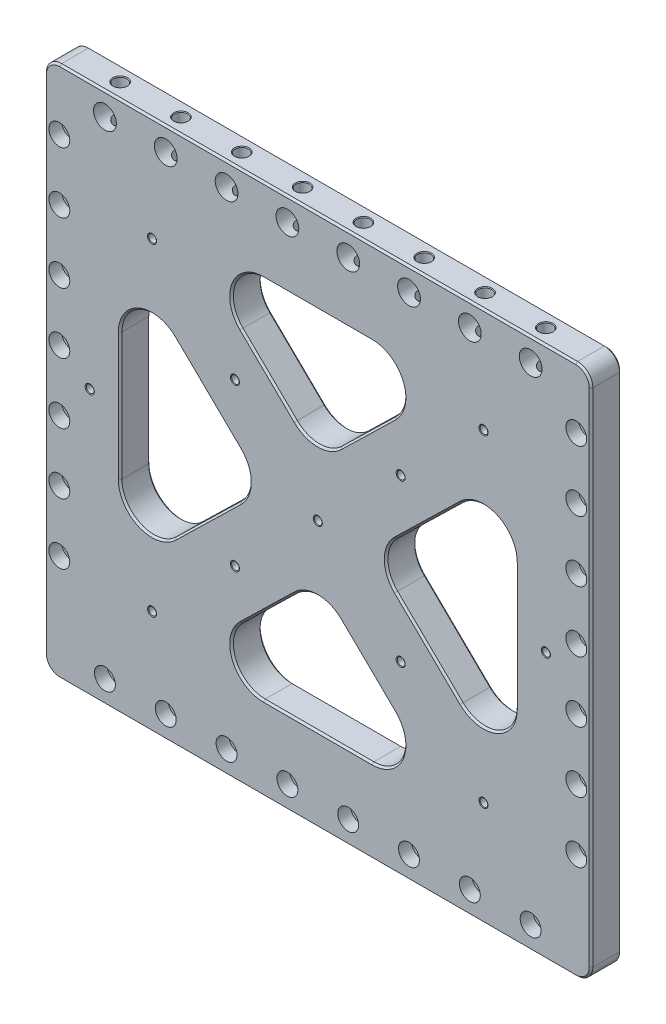
from build123d import *

# Parameters (mm, degrees)
SKETCH1_W                                     = 456.438
SKETCH1_H                                     = 444.5
EXTRUDE1_DEPTH                                = 12.7
CBORE_FOR_3_8_SOCKET_HEAD_CAP_SCREW1_AT_COUNT = 2
CBORE_FOR_3_8_SOCKET_HEAD_CAP_SCREW1_AT_PITCH = 431.8
LPATTERN1_COUNT                               = 4
LPATTERN1_PITCH                               = 50.8
LPATTERN1_COL_COUNT                           = 4
LPATTERN1_COL_PITCH                           = 50.8
TRIANGLES_CUT_EXTRUDE1_DEPTH                  = 26.4
FILLET1_R                                     = 26.67
F_3_4_0_75_DIAMETER_HOLE1_D                   = 19.05
LPATTERN3_COUNT                               = 5
LPATTERN3_PITCH                               = 50.8
LPATTERN3_COL_COUNT                           = 4
LPATTERN3_COL_PITCH                           = 50.8
F_1_4_20_TAPPED_HOLE1_AT_2_COUNT              = 2
F_1_4_20_TAPPED_HOLE1_AT_2_PITCH              = 96.61319845
F_1_4_20_TAPPED_HOLE1_AT_3_COUNT              = 2
F_1_4_20_TAPPED_HOLE1_AT_3_PITCH              = 213.731750641
F_1_4_20_TAPPED_HOLE1_AT_4_COUNT              = 2
F_1_4_20_TAPPED_HOLE1_AT_4_PITCH              = 134.809404563
F_1_4_20_TAPPED_HOLE1_AT_5_COUNT              = 2
F_1_4_20_TAPPED_HOLE1_AT_5_PITCH              = 193.226396899
F_1_4_20_TAPPED_HOLE1_AT_6_COUNT              = 2
F_1_4_20_TAPPED_HOLE1_AT_6_PITCH              = 289.839595349
F_1_4_20_TAPPED_HOLE1_AT_7_COUNT              = 2
F_1_4_20_TAPPED_HOLE1_AT_7_PITCH              = 218.311337119
F_1_4_20_TAPPED_HOLE1_AT_8_COUNT              = 2
F_1_4_20_TAPPED_HOLE1_AT_8_PITCH              = 138.43
F_1_4_20_TAPPED_HOLE1_AT_9_COUNT              = 2
F_1_4_20_TAPPED_HOLE1_AT_9_PITCH              = 96.61319845
F_1_4_20_TAPPED_HOLE1_AT_10_COUNT             = 2
F_1_4_20_TAPPED_HOLE1_AT_10_PITCH             = 268.319352852
F_1_4_20_TAPPED_HOLE1_AT_11_COUNT             = 2
F_1_4_20_TAPPED_HOLE1_AT_11_PITCH             = 138.756784031
FILLET2_R                                     = 12.7
CHAMFER1_SIZE                                 = 1.524


with BuildPart() as part:
    # Sketch1 → Extrude1 (new body, symmetric)
    with BuildSketch(Plane.XY):
        Rectangle(SKETCH1_W, SKETCH1_H)
    extrude(amount=EXTRUDE1_DEPTH, both=True)

    # Sketch2 → CBORE for 3_8 Socket Head Cap Screw1 (revolve, cut)
    with BuildSketch(Plane(origin=(-215.9, 19.05, 12.7), x_dir=(0, -1, 0), z_dir=(1, 0, 0))):
        Polygon((0, 0), (0, 25.4), (5.842, 25.4), (5.15874, 24.613999282), (5.15874, 10.668), (8.7376, 10.668), (8.7376, 0), align=None)
    cbore_for_3_8_socket_head_cap_screw1 = revolve(axis=Axis((-215.9, 19.05, 19.05), (0, 0, -1)), mode=Mode.SUBTRACT)

    # CBORE for 3_8 Socket Head Cap Screw1 at: CBORE for 3_8 Socket Head Cap Screw1 ×2
    with Locations(*[(i * CBORE_FOR_3_8_SOCKET_HEAD_CAP_SCREW1_AT_PITCH, 0, 0) for i in range(1, CBORE_FOR_3_8_SOCKET_HEAD_CAP_SCREW1_AT_COUNT)]):
        add(cbore_for_3_8_socket_head_cap_screw1, mode=Mode.SUBTRACT)

    # LPattern1: CBORE for 3_8 Socket Head Cap Screw1 ×4
    with Locations(*[(0, -i * LPATTERN1_PITCH, 0) for i in range(1, LPATTERN1_COUNT)]):
        add(cbore_for_3_8_socket_head_cap_screw1, mode=Mode.SUBTRACT)

    # LPattern1 copy 1 sketch → LPattern1 copy 1 (revolve, cut)
    with BuildSketch(Plane(origin=(215.9, -31.75, 12.7), x_dir=(0, -1, 0), z_dir=(1, 0, 0))):
        Polygon((0, 0), (0, 25.4), (5.842, 25.4), (5.15874, 24.613999282), (5.15874, 10.668), (8.7376, 10.668), (8.7376, 0), align=None)
    revolve(axis=Axis((215.9, -31.75, 19.05), (0, 0, -1)), mode=Mode.SUBTRACT)

    # LPattern1 copy 2 sketch → LPattern1 copy 2 (revolve, cut)
    with BuildSketch(Plane(origin=(215.9, -82.55, 12.7), x_dir=(0, -1, 0), z_dir=(1, 0, 0))):
        Polygon((0, 0), (0, 25.4), (5.842, 25.4), (5.15874, 24.613999282), (5.15874, 10.668), (8.7376, 10.668), (8.7376, 0), align=None)
    revolve(axis=Axis((215.9, -82.55, 19.05), (0, 0, -1)), mode=Mode.SUBTRACT)

    # LPattern1 copy 3 sketch → LPattern1 copy 3 (revolve, cut)
    with BuildSketch(Plane(origin=(215.9, -133.35, 12.7), x_dir=(0, -1, 0), z_dir=(1, 0, 0))):
        Polygon((0, 0), (0, 25.4), (5.842, 25.4), (5.15874, 24.613999282), (5.15874, 10.668), (8.7376, 10.668), (8.7376, 0), align=None)
    revolve(axis=Axis((215.9, -133.35, 19.05), (0, 0, -1)), mode=Mode.SUBTRACT)

    # LPattern1 col: CBORE for 3_8 Socket Head Cap Screw1 ×4
    with Locations(*[(0, i * LPATTERN1_COL_PITCH, 0) for i in range(1, LPATTERN1_COL_COUNT)]):
        add(cbore_for_3_8_socket_head_cap_screw1, mode=Mode.SUBTRACT)

    # LPattern1 col copy 1 sketch → LPattern1 col copy 1 (revolve, cut)
    with BuildSketch(Plane(origin=(215.9, 69.85, 12.7), x_dir=(0, -1, 0), z_dir=(1, 0, 0))):
        Polygon((0, 0), (0, 25.4), (5.842, 25.4), (5.15874, 24.613999282), (5.15874, 10.668), (8.7376, 10.668), (8.7376, 0), align=None)
    revolve(axis=Axis((215.9, 69.85, 19.05), (0, 0, -1)), mode=Mode.SUBTRACT)

    # LPattern1 col copy 2 sketch → LPattern1 col copy 2 (revolve, cut)
    with BuildSketch(Plane(origin=(215.9, 120.65, 12.7), x_dir=(0, -1, 0), z_dir=(1, 0, 0))):
        Polygon((0, 0), (0, 25.4), (5.842, 25.4), (5.15874, 24.613999282), (5.15874, 10.668), (8.7376, 10.668), (8.7376, 0), align=None)
    revolve(axis=Axis((215.9, 120.65, 19.05), (0, 0, -1)), mode=Mode.SUBTRACT)

    # LPattern1 col copy 3 sketch → LPattern1 col copy 3 (revolve, cut)
    with BuildSketch(Plane(origin=(215.9, 171.45, 12.7), x_dir=(0, -1, 0), z_dir=(1, 0, 0))):
        Polygon((0, 0), (0, 25.4), (5.842, 25.4), (5.15874, 24.613999282), (5.15874, 10.668), (8.7376, 10.668), (8.7376, 0), align=None)
    revolve(axis=Axis((215.9, 171.45, 19.05), (0, 0, -1)), mode=Mode.SUBTRACT)

    # Sketch10 → Triangles -- Cut-Extrude1 (cut, through all)
    with BuildSketch(Plane.XY.offset(12.7)):
        Polygon((-45.508235285, 0), (-165.1, -116.463877713), (-165.1, 116.463877713), align=None)
        Polygon((0, -44.31798094), (-110.984793286, -152.4), (110.984793286, -152.4), align=None)
        Polygon((45.508235285, 0), (165.1, -116.463877713), (165.1, 116.463877713), align=None)
        Polygon((0, 44.31798094), (110.984793286, 152.4), (-110.984793286, 152.4), align=None)
    extrude(amount=-TRIANGLES_CUT_EXTRUDE1_DEPTH, mode=Mode.SUBTRACT)

    # Fillet1
    fillet1_edges = [part.edges().sort_by_distance(p)[0] for p in [
        (0, 44.31798094, 0),
        (-110.984793286, 152.4, 0),
        (110.984793286, 152.4, 0),
        (-165.1, 116.463877713, 0),
        (-45.508235285, 0, 0),
        (-165.1, -116.463877713, 0),
        (110.984793286, -152.4, 0),
        (-110.984793286, -152.4, 0),
        (0, -44.31798094, 0),
        (45.508235285, 0, 0),
        (165.1, 116.463877713, 0),
        (165.1, -116.463877713, 0),
    ]]
    fillet(fillet1_edges, radius=FILLET1_R)

    # Sketch8 → CBORE for 3_8 Socket Head Cap Screw3 (revolve, cut)
    with BuildSketch(Plane(origin=(-25.4, -203.2, 12.7), x_dir=(0, -1, 0), z_dir=(1, 0, 0))):
        Polygon((0, 0), (0, 25.4), (5.842, 25.4), (5.15874, 24.613999282), (5.15874, 10.668), (8.7376, 10.668), (8.7376, 0), align=None)
    cbore_for_3_8_socket_head_cap_screw3 = revolve(axis=Axis((-25.4, -203.2, 19.05), (0, 0, -1)), mode=Mode.SUBTRACT)

    # 3_4 _0.75_ Diameter Hole1 (through all)
    with Locations(Plane.XY.offset(12.7)):
        with Locations((-25.4, 203.2)):
            f_3_4_0_75_diameter_hole1 = Hole(F_3_4_0_75_DIAMETER_HOLE1_D / 2)

    # Sketch14 → 7_16 _0.4375_ Diameter Hole1 (revolve, cut)
    with BuildSketch(Plane(origin=(-25.4, 222.25, 0), x_dir=(0, 0, 1), z_dir=(1, 0, 0))):
        Polygon((0, 0), (0, 38.263531814), (5.55625, 34.925), (5.55625, 0.620911348), (6.096, 0), align=None)
    f_7_16_0_4375_diameter_hole1 = revolve(axis=Axis((-25.4, 228.6, 0), (0, -1, 0)), mode=Mode.SUBTRACT)

    # LPattern3: CBORE for 3_8 Socket Head Cap Screw3, 3_4 _0.75_ Diameter Hole1, 7_16 _0.4375_ Diameter Hole1 ×5
    with Locations(*[(i * LPATTERN3_PITCH, 0, 0) for i in range(1, LPATTERN3_COUNT)]):
        add(cbore_for_3_8_socket_head_cap_screw3, mode=Mode.SUBTRACT)
        add(f_3_4_0_75_diameter_hole1, mode=Mode.SUBTRACT)
        add(f_7_16_0_4375_diameter_hole1, mode=Mode.SUBTRACT)

    # LPattern3 col: CBORE for 3_8 Socket Head Cap Screw3, 3_4 _0.75_ Diameter Hole1, 7_16 _0.4375_ Diameter Hole1 ×4
    with Locations(*[(-i * LPATTERN3_COL_PITCH, 0, 0) for i in range(1, LPATTERN3_COL_COUNT)]):
        add(cbore_for_3_8_socket_head_cap_screw3, mode=Mode.SUBTRACT)
        add(f_3_4_0_75_diameter_hole1, mode=Mode.SUBTRACT)
        add(f_7_16_0_4375_diameter_hole1, mode=Mode.SUBTRACT)

    # Sketch16 → 1_4-20 Tapped Hole1 (revolve, cut)
    with BuildSketch(Plane(origin=(-69.215, 67.404702282, 12.7), x_dir=(0, -1, 0), z_dir=(1, 0, 0))):
        Polygon((0, 0), (0, 25.4), (2.5527, 25.4), (2.5527, 12.7), (3.175, 12.7), (3.175, 0.366617421), (3.81, 0), align=None)
    f_1_4_20_tapped_hole1 = revolve(axis=Axis((-69.215, 67.404702282, 19.05), (0, 0, -1)), mode=Mode.SUBTRACT)

    # 1_4-20 Tapped Hole1 at 2: 1_4-20 Tapped Hole1 ×2
    with Locations(*[Vector(-0.716413504, 0.697675922, 0) * (i * F_1_4_20_TAPPED_HOLE1_AT_2_PITCH) for i in range(1, F_1_4_20_TAPPED_HOLE1_AT_2_COUNT)]):
        add(f_1_4_20_tapped_hole1, mode=Mode.SUBTRACT)

    # 1_4-20 Tapped Hole1 at 3: 1_4-20 Tapped Hole1 ×2
    with Locations(*[Vector(-0.323840514, -0.946111686, 0) * (i * F_1_4_20_TAPPED_HOLE1_AT_3_PITCH) for i in range(1, F_1_4_20_TAPPED_HOLE1_AT_3_COUNT)]):
        add(f_1_4_20_tapped_hole1, mode=Mode.SUBTRACT)

    # 1_4-20 Tapped Hole1 at 4: 1_4-20 Tapped Hole1 ×2
    with Locations(*[(0, -i * F_1_4_20_TAPPED_HOLE1_AT_4_PITCH, 0) for i in range(1, F_1_4_20_TAPPED_HOLE1_AT_4_COUNT)]):
        add(f_1_4_20_tapped_hole1, mode=Mode.SUBTRACT)

    # 1_4-20 Tapped Hole1 at 5: 1_4-20 Tapped Hole1 ×2
    with Locations(*[Vector(0.716413504, -0.697675922, 0) * (i * F_1_4_20_TAPPED_HOLE1_AT_5_PITCH) for i in range(1, F_1_4_20_TAPPED_HOLE1_AT_5_COUNT)]):
        add(f_1_4_20_tapped_hole1, mode=Mode.SUBTRACT)

    # 1_4-20 Tapped Hole1 at 6: 1_4-20 Tapped Hole1 ×2
    with Locations(*[Vector(0.716413504, -0.697675922, 0) * (i * F_1_4_20_TAPPED_HOLE1_AT_6_PITCH) for i in range(1, F_1_4_20_TAPPED_HOLE1_AT_6_COUNT)]):
        add(f_1_4_20_tapped_hole1, mode=Mode.SUBTRACT)

    # 1_4-20 Tapped Hole1 at 7: 1_4-20 Tapped Hole1 ×2
    with Locations(*[Vector(0.951141625, 0.308754933, 0) * (i * F_1_4_20_TAPPED_HOLE1_AT_7_PITCH) for i in range(1, F_1_4_20_TAPPED_HOLE1_AT_7_COUNT)]):
        add(f_1_4_20_tapped_hole1, mode=Mode.SUBTRACT)

    # 1_4-20 Tapped Hole1 at 8: 1_4-20 Tapped Hole1 ×2
    with Locations(*[(i * F_1_4_20_TAPPED_HOLE1_AT_8_PITCH, 0, 0) for i in range(1, F_1_4_20_TAPPED_HOLE1_AT_8_COUNT)]):
        add(f_1_4_20_tapped_hole1, mode=Mode.SUBTRACT)

    # 1_4-20 Tapped Hole1 at 9: 1_4-20 Tapped Hole1 ×2
    with Locations(*[Vector(0.716413504, -0.697675922, 0) * (i * F_1_4_20_TAPPED_HOLE1_AT_9_PITCH) for i in range(1, F_1_4_20_TAPPED_HOLE1_AT_9_COUNT)]):
        add(f_1_4_20_tapped_hole1, mode=Mode.SUBTRACT)

    # 1_4-20 Tapped Hole1 at 10: 1_4-20 Tapped Hole1 ×2
    with Locations(*[Vector(0.967932418, -0.251210737, 0) * (i * F_1_4_20_TAPPED_HOLE1_AT_10_PITCH) for i in range(1, F_1_4_20_TAPPED_HOLE1_AT_10_COUNT)]):
        add(f_1_4_20_tapped_hole1, mode=Mode.SUBTRACT)

    # 1_4-20 Tapped Hole1 at 11: 1_4-20 Tapped Hole1 ×2
    with Locations(*[Vector(-0.874083389, -0.485775905, 0) * (i * F_1_4_20_TAPPED_HOLE1_AT_11_PITCH) for i in range(1, F_1_4_20_TAPPED_HOLE1_AT_11_COUNT)]):
        add(f_1_4_20_tapped_hole1, mode=Mode.SUBTRACT)

    # Fillet2
    fillet2_edges = [part.edges().sort_by_distance(p)[0] for p in [
        (-228.219, 222.25, 0),
        (228.219, 222.25, 0),
        (228.219, -222.25, 0),
        (-228.219, -222.25, 0),
    ]]
    fillet(fillet2_edges, radius=FILLET2_R)

    # Chamfer1
    chamfer1_edges = [part.edges().sort_by_distance(p)[0] for p in [
        (0, -152.4, 12.7),
        (0, -152.4, -12.7),
        (-41.292814656, -84.530794323, 12.7),
        (-41.292814656, -84.530794323, -12.7),
        (41.292814656, -84.530794323, 12.7),
        (41.292814656, -84.530794323, -12.7),
        (165.1, 0, 12.7),
        (165.1, 0, -12.7),
        (92.47555963, -45.738907959, 12.7),
        (92.47555963, -45.738907959, -12.7),
        (92.47555963, 45.738907959, 12.7),
        (92.47555963, 45.738907959, -12.7),
        (0, 152.4, 12.7),
        (0, 152.4, -12.7),
        (41.292814656, 84.530794323, 12.7),
        (41.292814656, 84.530794323, -12.7),
        (-41.292814656, 84.530794323, 12.7),
        (-41.292814656, 84.530794323, -12.7),
        (-165.1, 0, 12.7),
        (-165.1, 0, -12.7),
        (-92.47555963, 45.738907959, 12.7),
        (-92.47555963, 45.738907959, -12.7),
        (-92.47555963, -45.738907959, 12.7),
        (-92.47555963, -45.738907959, -12.7),
        (-70.078536705, -135.772706982, 12.7),
        (-70.078536705, -135.772706982, -12.7),
        (0, -54.87508493, 12.7),
        (0, -54.87508493, -12.7),
        (70.078536705, -135.772706982, 12.7),
        (70.078536705, -135.772706982, -12.7),
        (148.799179357, -77.836031406, 12.7),
        (148.799179357, -77.836031406, -12.7),
        (57.065152925, 0, 12.7),
        (57.065152925, 0, -12.7),
        (148.799179357, 77.836031406, 12.7),
        (148.799179357, 77.836031406, -12.7),
        (70.078536705, 135.772706982, 12.7),
        (70.078536705, 135.772706982, -12.7),
        (0, 54.87508493, 12.7),
        (0, 54.87508493, -12.7),
        (-70.078536705, 135.772706982, 12.7),
        (-70.078536705, 135.772706982, -12.7),
        (-148.799179357, 77.836031406, 12.7),
        (-148.799179357, 77.836031406, -12.7),
        (-57.065152925, 0, 12.7),
        (-57.065152925, 0, -12.7),
        (-148.799179357, -77.836031406, 12.7),
        (-148.799179357, -77.836031406, -12.7),
        (0, -222.25, -12.7),
        (0, -222.25, 12.7),
        (-228.219, 0, -12.7),
        (0, 222.25, -12.7),
        (228.219, 0, -12.7),
        (-224.499256121, 218.530256121, -12.7),
        (224.499256121, 218.530256121, -12.7),
        (224.499256121, -218.530256121, -12.7),
        (-224.499256121, -218.530256121, -12.7),
        (-228.219, 0, 12.7),
        (228.219, 0, 12.7),
        (0, 222.25, 12.7),
        (-224.499256121, 218.530256121, 12.7),
        (224.499256121, 218.530256121, 12.7),
        (224.499256121, -218.530256121, 12.7),
        (-224.499256121, -218.530256121, 12.7),
    ]]
    chamfer(chamfer1_edges, length=CHAMFER1_SIZE)


solid = part.part
